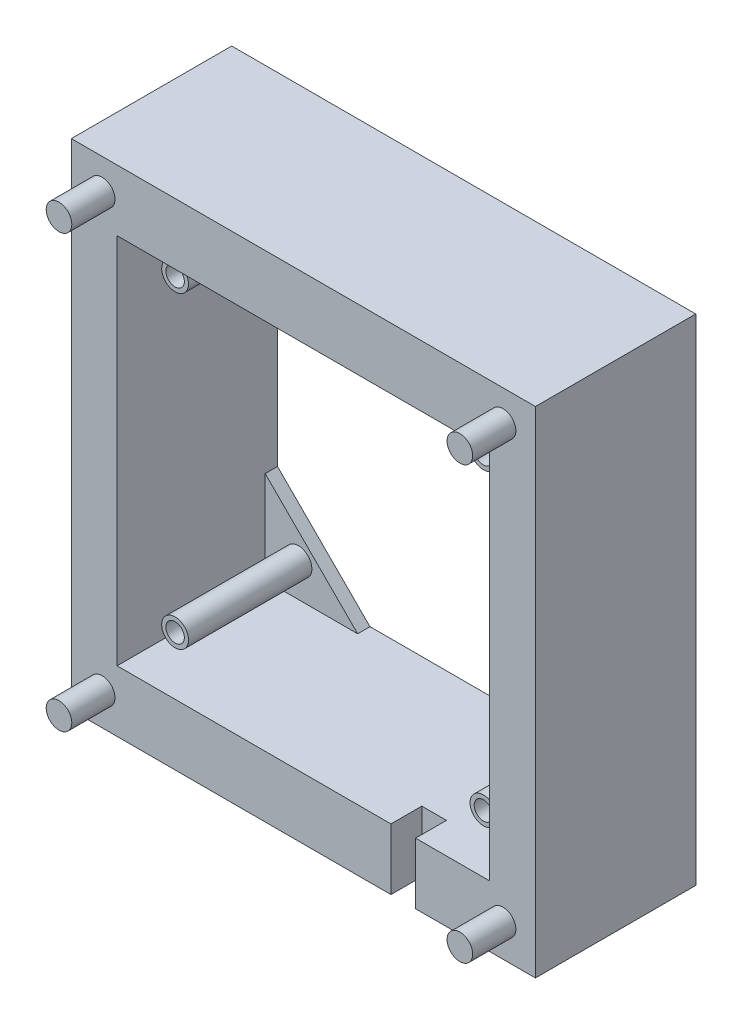
from build123d import *

# Parameters (mm, degrees)
CROQUIS1_W              = 75.25
CROQUIS1_H              = 80.25
CROQUIS1_W_2            = 60.4
CROQUIS1_H_2            = 60.4
SALIENTE_EXTRUIR1_DEPTH = 24
CROQUIS2_R              = 2.075
SALIENTE_EXTRUIR2_DEPTH = 7
CROQUIS3_R              = 1.5
SALIENTE_EXTRUIR3_DEPTH = 2
CROQUIS4_R              = 2.175
CROQUIS4_R_2            = 1.5
SALIENTE_EXTRUIR4_DEPTH = 20
CROQUIS5_W              = 4
CROQUIS5_H              = 5
CORTAR_EXTRUIR1_DEPTH   = 9.925
SALIENTE_EXTRUIR5_DEPTH = 2


with BuildPart() as part:
    # Croquis1 → Saliente-Extruir1 (new body)
    with BuildSketch(Plane.XY):
        with Locations((-58.191304348, -12.068115942)):
            Rectangle(CROQUIS1_W, CROQUIS1_H)
        with Locations((-58.191304348, -12.068115942)):
            Rectangle(CROQUIS1_W_2, CROQUIS1_H_2, mode=Mode.SUBTRACT)
    extrude(amount=SALIENTE_EXTRUIR1_DEPTH)

    # Croquis2 → Saliente-Extruir2 (add)
    with BuildSketch(Plane.XY.offset(24)):
        with Locations((-90.816304348, 23.056884058)):
            Circle(CROQUIS2_R)
        with Locations((-25.816304348, 23.056884058)):
            Circle(CROQUIS2_R)
        with Locations((-25.816304348, -46.943115942)):
            Circle(CROQUIS2_R)
        with Locations((-90.816304348, -46.943115942)):
            Circle(CROQUIS2_R)
    extrude(amount=SALIENTE_EXTRUIR2_DEPTH)

    # Croquis3 → Saliente-Extruir3 (add)
    with BuildSketch(Plane(origin=(0, 0, 0), x_dir=(-1, 0, 0), z_dir=(0, 0, -1))):
        Polygon((20.566304348, -19.843115942), (20.566304348, -52.193115942), (52.916304348, -52.193115942), align=None)
        with Locations((32.991304348, -36.868115942)):
            Circle(CROQUIS3_R, mode=Mode.SUBTRACT)
        Polygon((95.816304348, -4.293115942), (95.816304348, 28.056884058), (63.466304348, 28.056884058), align=None)
        with Locations((82.991304348, 13.131884058)):
            Circle(CROQUIS3_R, mode=Mode.SUBTRACT)
        Polygon((95.816304348, -19.843115942), (63.466304348, -52.193115942), (95.816304348, -52.193115942), align=None)
        with Locations((82.991304348, -36.868115942)):
            Circle(CROQUIS3_R, mode=Mode.SUBTRACT)
        Polygon((20.566304348, -4.293115942), (52.916304348, 28.056884058), (20.566304348, 28.056884058), align=None)
        with Locations((32.991304348, 13.131884058)):
            Circle(CROQUIS3_R, mode=Mode.SUBTRACT)
    extrude(amount=SALIENTE_EXTRUIR3_DEPTH)

    # Croquis4 → Saliente-Extruir4 (add)
    with BuildSketch(Plane.XY):
        with Locations((-82.991304348, 13.131884058)):
            Circle(CROQUIS4_R)
        with Locations((-82.991304348, 13.131884058)):
            Circle(CROQUIS4_R_2, mode=Mode.SUBTRACT)
        with Locations((-32.991304348, 13.131884058)):
            Circle(CROQUIS4_R)
        with Locations((-32.991304348, 13.131884058)):
            Circle(CROQUIS4_R_2, mode=Mode.SUBTRACT)
        with Locations((-32.991304348, -36.868115942)):
            Circle(CROQUIS4_R)
        with Locations((-32.991304348, -36.868115942)):
            Circle(CROQUIS4_R_2, mode=Mode.SUBTRACT)
        with Locations((-82.991304348, -36.868115942)):
            Circle(CROQUIS4_R)
        with Locations((-82.991304348, -36.868115942)):
            Circle(CROQUIS4_R_2, mode=Mode.SUBTRACT)
    extrude(amount=SALIENTE_EXTRUIR4_DEPTH)

    # Croquis5 → Cortar-Extruir1 (cut)
    with BuildSketch(Plane(origin=(0, -42.268115942, 0), x_dir=(1, 0, 0), z_dir=(0, 1, 0))):
        with Locations((-41.991304348, -21.5)):
            Rectangle(CROQUIS5_W, CROQUIS5_H)
    extrude(amount=-CORTAR_EXTRUIR1_DEPTH, mode=Mode.SUBTRACT)

    # Croquis6 → Saliente-Extruir5 (add)
    with BuildSketch(Plane(origin=(0, 0, 0), x_dir=(-1, 0, 0), z_dir=(0, 0, -1))):
        Polygon((42.991304348, 18.131884058), (52.916304348, 28.056884058), (63.466304348, 28.056884058), (73.391304348, 18.131884058), align=None)
        Polygon((27.991304348, 3.131884058), (27.991304348, -27.268115942), (20.566304348, -19.843115942), (20.566304348, -4.293115942), align=None)
        Polygon((42.991304348, -42.268115942), (52.916304348, -52.193115942), (63.466304348, -52.193115942), (73.391304348, -42.268115942), align=None)
        Polygon((88.391304348, -27.268115942), (88.391304348, 3.131884058), (95.816304348, -4.293115942), (95.816304348, -19.843115942), align=None)
    extrude(amount=SALIENTE_EXTRUIR5_DEPTH)


solid = part.part
